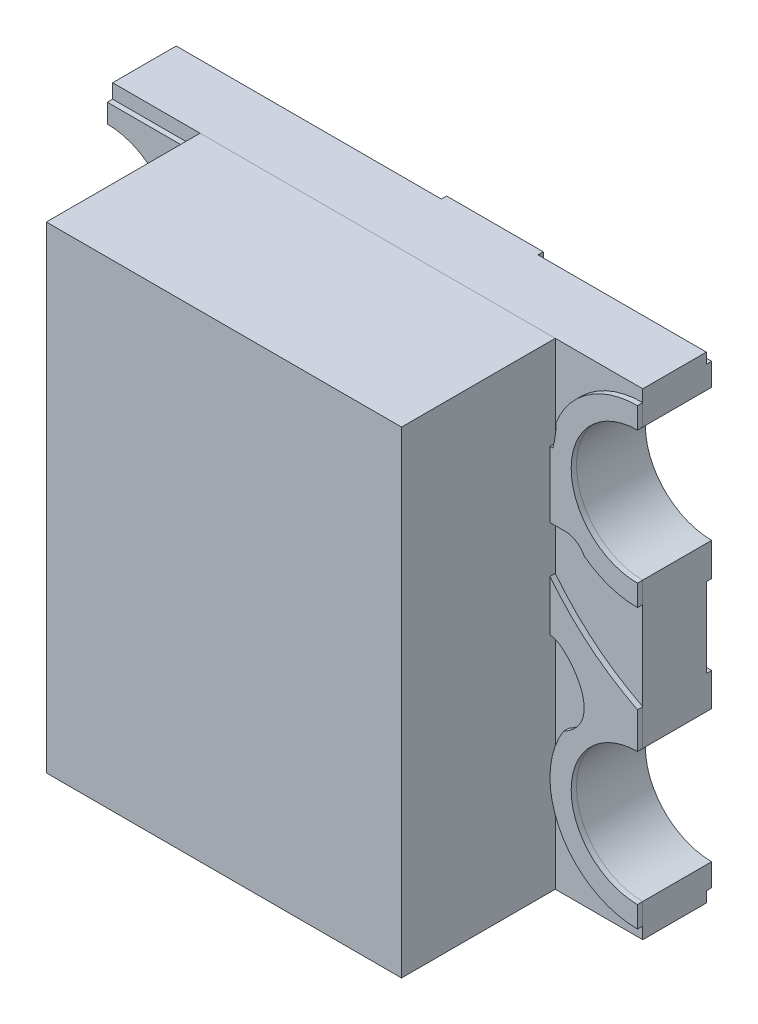
from build123d import *

# Parameters (mm, degrees)
BOSS_EXTRUDE1_DEPTH   = 0.24
SKETCH3_W             = 0.364889656
SKETCH3_H             = 1.8
BOSS_EXTRUDE2_DEPTH   = 0.02
BOSS_EXTRUDE3_DEPTH   = 0.02
BOSS_EXTRUDE3_2_DEPTH = 0.02
BOSS_EXTRUDE3_3_DEPTH = 0.02
BOSS_EXTRUDE3_4_DEPTH = 0.02
SKETCH5_W             = 0.753896915
SKETCH5_H             = 0.410580729
BOSS_EXTRUDE4_DEPTH   = 0.021
SKETCH5_W_2           = 0.173666543
SKETCH5_H_2           = 0.172266029
BOSS_EXTRUDE4_2_DEPTH = 0.021
SKETCH5_W_3           = 0.103954437
BOSS_EXTRUDE4_3_DEPTH = 0.021
SKETCH5_W_4           = 0.090039485
BOSS_EXTRUDE4_4_DEPTH = 0.021
SKETCH6_W             = 1.34
SKETCH6_H             = 1.8
BOSS_EXTRUDE5_DEPTH   = 0.58


with BuildPart() as part:
    # Sketch2 → Boss-Extrude1 (new body)
    with BuildSketch(Plane(origin=(0, 0, 0.02), x_dir=(-1, 0, 0), z_dir=(0, 0, -1))):
        with BuildLine():
            Line((1, -0.9), (-1, -0.9))
            Line((-1, -0.9), (-1, -0.775))
            ThreePointArc((-1, -0.775), (-0.75, -0.525), (-1, -0.275))
            Line((-1, -0.275), (-1, 0.275))
            ThreePointArc((-1, 0.275), (-0.75, 0.525), (-1, 0.775))
            Line((-1, 0.775), (-1, 0.9))
            Line((-1, 0.9), (1, 0.9))
            Line((1, 0.9), (1, 0.775))
            ThreePointArc((1, 0.775), (0.75, 0.525), (1, 0.275))
            Line((1, 0.275), (1, -0.275))
            ThreePointArc((1, -0.275), (0.75, -0.525), (1, -0.775))
            Line((1, -0.775), (1, -0.9))
        make_face()
    extrude(amount=-BOSS_EXTRUDE1_DEPTH)

    # Sketch3 → Boss-Extrude2 (add)
    with BuildSketch(Plane(origin=(0, 0, 0.02), x_dir=(-1, 0, 0), z_dir=(0, 0, -1))):
        with BuildLine():
            ThreePointArc((-1, 0.775), (-0.75, 0.525), (-1, 0.275))
            Line((-1, 0.275), (-1, 0.15))
            Line((-1, 0.15), (-0.53, 0.15))
            Line((-0.53, 0.15), (-0.53, 0.86))
            Line((-0.53, 0.86), (-1, 0.86))
            Line((-1, 0.86), (-1, 0.775))
        make_face()
        with BuildLine():
            Line((1, 0.775), (1, 0.86))
            Line((1, 0.86), (0.53, 0.86))
            Line((0.53, 0.86), (0.53, 0.15))
            Line((0.53, 0.15), (1, 0.15))
            Line((1, 0.15), (1, 0.275))
            ThreePointArc((1, 0.275), (0.75, 0.525), (1, 0.775))
        make_face()
        with BuildLine():
            Line((0.53, -0.86), (1, -0.86))
            Line((1, -0.86), (1, -0.775))
            ThreePointArc((1, -0.775), (0.75, -0.525), (1, -0.275))
            Line((1, -0.275), (1, -0.15))
            Line((1, -0.15), (0.53, -0.15))
            Line((0.53, -0.15), (0.53, -0.86))
        make_face()
        with BuildLine():
            Line((-0.53, -0.15), (-1, -0.15))
            Line((-1, -0.15), (-1, -0.275))
            ThreePointArc((-1, -0.275), (-0.75, -0.525), (-1, -0.775))
            Line((-1, -0.775), (-1, -0.86))
            Line((-1, -0.86), (-0.53, -0.86))
            Line((-0.53, -0.86), (-0.53, -0.15))
        make_face()
        with Locations((-0.182444828, 0)):
            Rectangle(SKETCH3_W, SKETCH3_H)
    extrude(amount=BOSS_EXTRUDE2_DEPTH)


with BuildPart() as body_2:
    # Sketch4 → Boss-Extrude3 (new body)
    with BuildSketch(Plane.XY.offset(0.26)):
        with BuildLine():
            Line((0.390148762, 0.846389186), (-0.69066899, 0.846389186))
            add(Edge.make_bspline(
                [(-0.69066899, 0.846389186), (-0.845334495, 0.846389186), (-1, 0.846389186)],
                knots=[0, 0, 0, 1, 1, 1], degree=2))
            Line((-1, 0.846389186), (-1, 0.775))
            ThreePointArc((-1, 0.775), (-0.75, 0.525), (-1, 0.275))
            Line((-1, 0.275), (-1, 0.186389186))
            ThreePointArc((-1, 0.186389186), (-0.715345164, 0.349441217), (-0.711984565, 0.677470251))
            add(Edge.make_bspline(
                [(-0.676691892, 0.685575063), (-0.694152628, 0.680731002), (-0.711984565, 0.677470251)],
                knots=[0, 0, 0, 1, 1, 1], degree=2))
            Line((-0.676691892, 0.685575063), (0.390148762, 0.685575063))
            Line((0.390148762, 0.685575063), (0.390148762, 0.846389186))
        make_face()
    extrude(amount=BOSS_EXTRUDE3_DEPTH)


with BuildPart() as body_3:
    # Sketch4 → Boss-Extrude3 2 (new body)
    with BuildSketch(Plane.XY.offset(0.26)):
        with BuildLine():
            Line((1, 0.775), (1, 0.855))
            ThreePointArc((1, 0.855), (0.814516991, 0.797939651), (0.69317777, 0.646491232))
            add(Edge.make_bspline(
                [(0.680908874, 0.556929298), (0.69288427, 0.60085648), (0.69317777, 0.646491232)],
                knots=[0, 0, 0, 1, 1, 1], degree=2))
            Line((0.680908874, 0.556929298), (-0.503543763, 0.556929298))
            ThreePointArc((-0.503543763, 0.556929298), (-0.574254441, 0.527639976), (-0.603543763, 0.456929298))
            Line((-0.603543763, 0.456929298), (-0.603543763, 0.04290495))
            ThreePointArc((-0.603543763, 0.04290495), (-0.574254441, -0.027805728), (-0.503543763, -0.05709505))
            Line((-0.503543763, -0.05709505), (0.312415517, -0.05709505))
            ThreePointArc((0.312415517, -0.05709505), (0.383126195, -0.027805728), (0.412415517, 0.04290495))
            Line((0.412415517, 0.04290495), (0.412415517, 0.208081796))
            ThreePointArc((0.412415517, 0.208081796), (0.441704839, 0.278792474), (0.512415517, 0.308081796))
            Line((0.512415517, 0.308081796), (0.717469575, 0.308081796))
            add(Edge.make_bspline(
                [(0.717469575, 0.308081796), (0.771233684, 0.311754034), (0.799786818, 0.262674474)],
                knots=[0, 0, 0, 1, 1, 1], degree=2))
            ThreePointArc((0.799786818, 0.262674474), (0.894329341, 0.212376086), (1, 0.195))
            Line((1, 0.195), (1, 0.275))
            ThreePointArc((1, 0.275), (0.75, 0.525), (1, 0.775))
        make_face()
    extrude(amount=BOSS_EXTRUDE3_2_DEPTH)


with BuildPart() as body_4:
    # Sketch4 → Boss-Extrude3 3 (new body)
    with BuildSketch(Plane.XY.offset(0.26)):
        with BuildLine():
            ThreePointArc((-0.833334938, -0.24017943), (-0.91365994, -0.206495064), (-1, -0.195))
            Line((-1, -0.195), (-1, -0.275))
            ThreePointArc((-1, -0.275), (-0.75, -0.525), (-1, -0.775))
            Line((-1, -0.775), (-1, -0.855))
            ThreePointArc((-1, -0.855), (-0.795148632, -0.783719765), (-0.678793346, -0.600672224))
            Line((-0.678793346, -0.600672224), (-0.676691892, -0.554145089))
            Line((-0.676691892, -0.554145089), (-0.611118313, -0.607286747))
            ThreePointArc((-0.611118313, -0.607286747), (-0.583813147, -0.641943472), (-0.574079844, -0.684977452))
            Line((-0.574079844, -0.684977452), (-0.574079844, -0.767129551))
            Line((-0.574079844, -0.767129551), (0.535920392, -0.767129551))
            Line((0.535920392, -0.767129551), (0.535920392, -0.20656652))
            Line((0.535920392, -0.20656652), (-0.603543763, -0.20656652))
            ThreePointArc((-0.603543763, -0.20656652), (-0.635114964, -0.211681014), (-0.66345675, -0.226501334))
            add(Edge.make_bspline(
                [(-0.66345675, -0.226501334), (-0.689269713, -0.245817241), (-0.725525791, -0.251252887), (-0.800759226, -0.260738541), (-0.833334938, -0.24017943)],
                knots=[0.089775833, 0.089775833, 0.089775833, 0.089775833, 0.400476653, 1, 1, 1, 1], degree=3))
        make_face()
    extrude(amount=BOSS_EXTRUDE3_3_DEPTH)


with BuildPart() as body_5:
    # Sketch4 → Boss-Extrude3 4 (new body)
    with BuildSketch(Plane.XY.offset(0.26)):
        with BuildLine():
            Line((1, -0.275), (1, -0.138574493))
            add(Edge.make_bspline(
                [(1, -0.138574493), (0.779830968, -0.026964761), (0.636027007, 0.177640765)],
                knots=[0, 0, 0, 1, 1, 1], degree=2))
            Line((0.636027007, 0.177640765), (0.535920392, 0.177640765))
            Line((0.535920392, 0.177640765), (0.535920392, -0.05709505))
            Line((0.535920392, -0.05709505), (0.653476764, -0.05709505))
            ThreePointArc((0.653476764, -0.05709505), (0.687503608, -0.063062216), (0.717469575, -0.080251572))
            add(Edge.make_bspline(
                [(0.717469575, -0.080251572), (0.785860125, -0.137205052), (0.858637114, -0.27404228), (0.721239787, -0.348385325)],
                knots=[0.124405165, 0.124405165, 0.124405165, 0.124405165, 1, 1, 1, 1], degree=3))
            ThreePointArc((0.721239787, -0.348385325), (0.710878189, -0.684086702), (1, -0.855))
            Line((1, -0.855), (1, -0.775))
            ThreePointArc((1, -0.775), (0.75, -0.525), (1, -0.275))
        make_face()
    extrude(amount=BOSS_EXTRUDE3_4_DEPTH)


with BuildPart() as body_6:
    # Sketch5 → Boss-Extrude4 (new body)
    with BuildSketch(Plane.XY.offset(0.26)):
        with Locations((-0.057365299, 0.245704269)):
            Rectangle(SKETCH5_W, SKETCH5_H)
    extrude(amount=BOSS_EXTRUDE4_DEPTH)


with BuildPart() as body_7:
    # Sketch5 → Boss-Extrude4 2 (new body)
    with BuildSketch(Plane.XY.offset(0.26)):
        with Locations((-0.030990211, -0.445513551)):
            Rectangle(SKETCH5_W_2, SKETCH5_H_2)
    extrude(amount=BOSS_EXTRUDE4_2_DEPTH)


with BuildPart() as body_8:
    # Sketch5 → Boss-Extrude4 3 (new body)
    with BuildSketch(Plane.XY.offset(0.26)):
        with Locations((-0.361571177, -0.445513551)):
            Rectangle(SKETCH5_W_3, SKETCH5_H_2)
    extrude(amount=BOSS_EXTRUDE4_3_DEPTH)


with BuildPart() as body_9:
    # Sketch5 → Boss-Extrude4 4 (new body)
    with BuildSketch(Plane.XY.offset(0.26)):
        with Locations((0.298247329, -0.445513551)):
            Rectangle(SKETCH5_W_4, SKETCH5_H_2)
    extrude(amount=BOSS_EXTRUDE4_4_DEPTH)


with BuildPart() as body_10:
    # Sketch6 → Boss-Extrude5 (new body)
    with BuildSketch(Plane.XY.offset(0.26)):
        Rectangle(SKETCH6_W, SKETCH6_H)
    extrude(amount=BOSS_EXTRUDE5_DEPTH)


solid = Compound([part.part, body_2.part, body_3.part, body_4.part, body_5.part, body_6.part, body_7.part, body_8.part, body_9.part, body_10.part])
